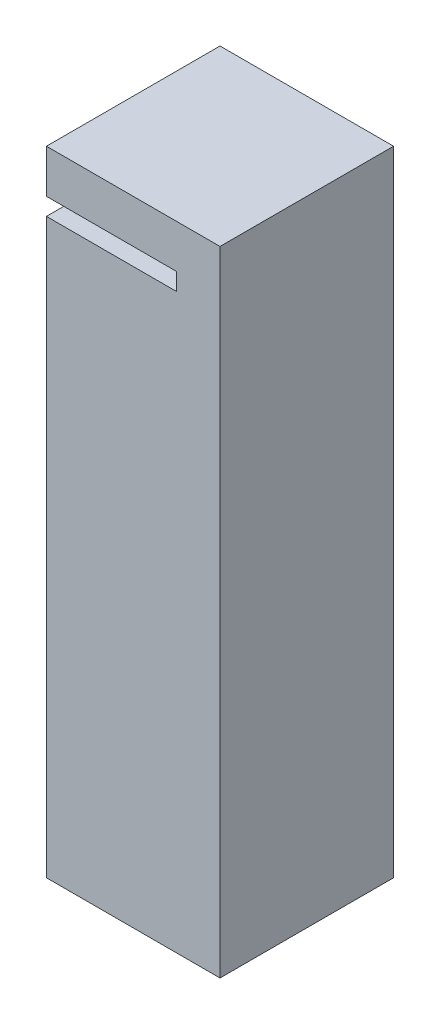
from build123d import *

# Parameters (mm, degrees)
ESBO_O1_W                = 40
ESBO_O1_H                = 40
RESSALTO_EXTRUS_O1_DEPTH = 10
RESSALTO_EXTRUS_O2_DEPTH = 136
ESBO_O3_W                = 30
ESBO_O3_H                = 10
RESSALTO_EXTRUS_O3_DEPTH = 30
ESBO_O4_W                = 30
ESBO_O4_H                = 4
CORTE_EXTRUS_O1_DEPTH    = 11


with BuildPart() as part:
    # Esboço1 → Ressalto-extrusão1 (new body)
    with BuildSketch(Plane(origin=(0, 0, 0), x_dir=(1, 0, 0), z_dir=(0, 1, 0))):
        with Locations((20, -20)):
            Rectangle(ESBO_O1_W, ESBO_O1_H)
    extrude(amount=RESSALTO_EXTRUS_O1_DEPTH)

    # Esboço2 → Ressalto-extrusão2 (add)
    with BuildSketch(Plane(origin=(0, 10, 0), x_dir=(1, 0, 0), z_dir=(0, 1, 0))):
        Polygon((40, 0), (30, 0), (30, -30), (0, -30), (0, -40), (40, -40), align=None)
    extrude(amount=RESSALTO_EXTRUS_O2_DEPTH)

    # Esboço3 → Ressalto-extrusão3 (add)
    with BuildSketch(Plane(origin=(0, 0, 30), x_dir=(-1, 0, 0), z_dir=(0, 0, -1))):
        with Locations((-15, 141)):
            Rectangle(ESBO_O3_W, ESBO_O3_H)
        with Locations((-15, 127)):
            Rectangle(ESBO_O3_W, ESBO_O3_H)
    extrude(amount=RESSALTO_EXTRUS_O3_DEPTH)

    # Esboço4 → Corte-extrusão1 (cut, through all)
    with BuildSketch(Plane(origin=(0, 0, 30), x_dir=(-1, 0, 0), z_dir=(0, 0, -1))):
        with Locations((-15, 134)):
            Rectangle(ESBO_O4_W, ESBO_O4_H)
    extrude(amount=-CORTE_EXTRUS_O1_DEPTH, mode=Mode.SUBTRACT)


solid = part.part
